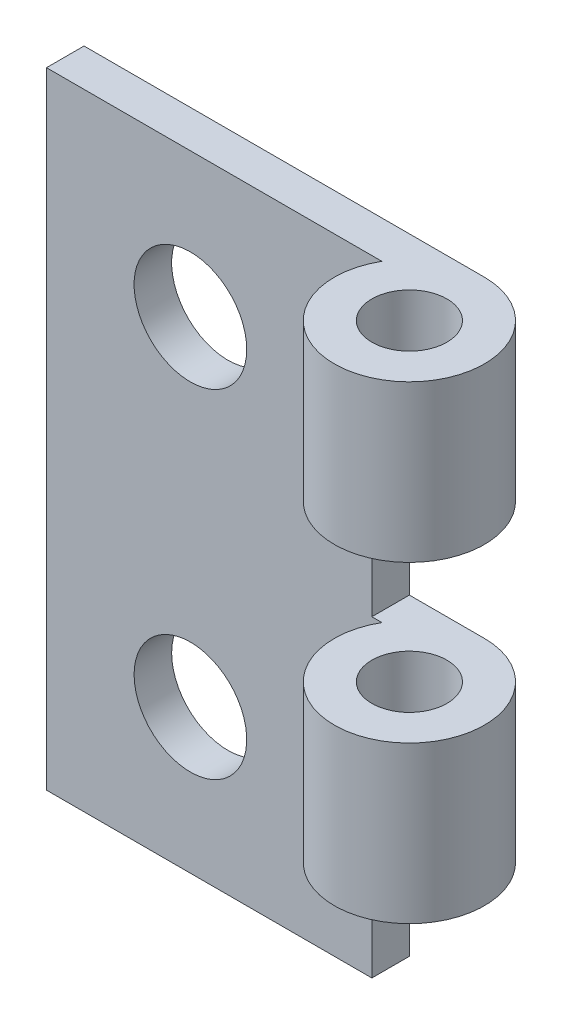
from build123d import *

# Parameters (mm, degrees)
SKETCH_1_W          = 13
SKETCH_1_H          = 25
SKETCH_1_R          = 2.25
EXTRUDE_1_DEPTH     = 1.5
SKETCH_2_R          = 3
SKETCH_2_R_2        = 1.5
EXTRUDE_2_DEPTH     = 25
SKETCH_3_W          = 3
SKETCH_3_H          = 25
EXTRUDE_3_DEPTH     = 1.5
SKETCH_4_W          = 6
SKETCH_4_H          = 6.25
CUT_EXTRUDE_1_DEPTH = 7


with BuildPart() as part:
    # 草图1 → 凸台-拉伸1 (new body)
    with BuildSketch(Plane.XY):
        Rectangle(SKETCH_1_W, SKETCH_1_H)
        with Locations((-0.75, 6.75)):
            Circle(SKETCH_1_R, mode=Mode.SUBTRACT)
        with Locations((-0.75, -6.75)):
            Circle(SKETCH_1_R, mode=Mode.SUBTRACT)
    extrude(amount=EXTRUDE_1_DEPTH)



with BuildPart() as body_2:
    # 草图2 → 凸台-拉伸2 (new body)
    with BuildSketch(Plane.XZ.offset(12.5)):
        with Locations((9.5, 3)):
            Circle(SKETCH_2_R)
        with Locations((9.5, 3)):
            Circle(SKETCH_2_R_2, mode=Mode.SUBTRACT)
    extrude(amount=-EXTRUDE_2_DEPTH)


with BuildPart() as part_1:
    add(part.part)

    add(body_2.part)  # 凸台-拉伸3 merges body 2
    # 草图3 → 凸台-拉伸3 (add)
    with BuildSketch(Plane(origin=(0, 0, 0), x_dir=(-1, 0, 0), z_dir=(0, 0, -1))):
        with Locations((-8, 0)):
            Rectangle(SKETCH_3_W, SKETCH_3_H)
    extrude(amount=-EXTRUDE_3_DEPTH)

    # 草图4 → 切除-拉伸1 (cut, through all)
    with BuildSketch(Plane(origin=(0, 0, 0), x_dir=(-1, 0, 0), z_dir=(0, 0, -1))):
        with Locations((-9.5, -9.375)):
            Rectangle(SKETCH_4_W, SKETCH_4_H)
        with Locations((-9.5, 3.125)):
            Rectangle(SKETCH_4_W, SKETCH_4_H)
    extrude(amount=-CUT_EXTRUDE_1_DEPTH, mode=Mode.SUBTRACT)


solid = part_1.part
